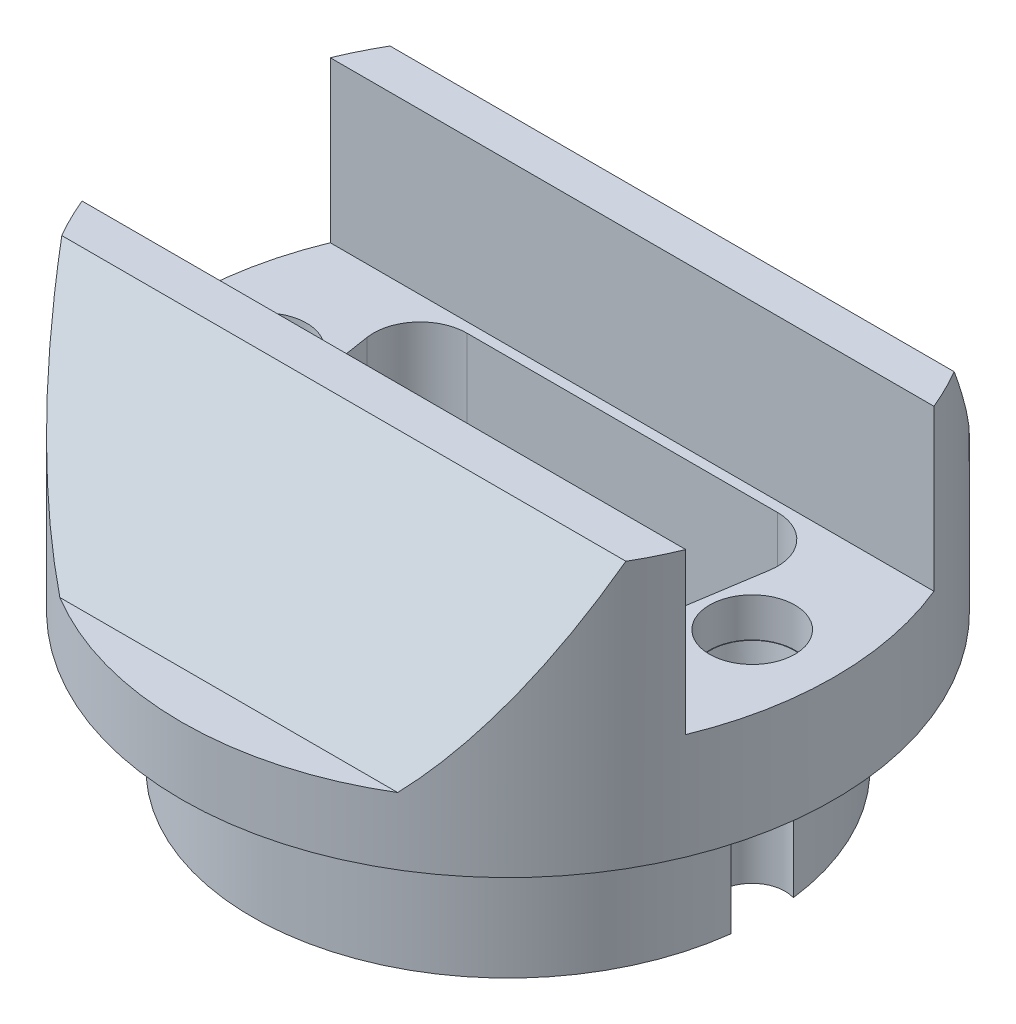
from build123d import *

# Parameters (mm, degrees)
SKETCH1_R           = 13.1
BOSS_EXTRUDE1_DEPTH = 7
SKETCH2_R           = 16.7
BOSS_EXTRUDE2_DEPTH = 3.429
CUT_EXTRUDE1_DEPTH  = 11.429
SKETCH5_R           = 2.159
CUT_EXTRUDE2_DEPTH  = 3.429
CUT_EXTRUDE2_TAPER  = 8
CUT_EXTRUDE3_DEPTH  = 8
SKETCH7_R           = 16.7
BOSS_EXTRUDE3_DEPTH = 10.2
SKETCH9_W           = 12.7
SKETCH9_H           = 10.2
CUT_EXTRUDE4_DEPTH  = 34.4
SKETCH10_R          = 2.1844
BOSS_EXTRUDE4_DEPTH = 2


with BuildPart() as part:
    # Sketch1 → Boss-Extrude1 (new body)
    with BuildSketch(Plane(origin=(0, 0, 0), x_dir=(1, 0, 0), z_dir=(0, 1, 0))):
        Circle(SKETCH1_R)
    extrude(amount=BOSS_EXTRUDE1_DEPTH)

    # Sketch2 → Boss-Extrude2 (add)
    with BuildSketch(Plane(origin=(0, 7, 0), x_dir=(1, 0, 0), z_dir=(0, 1, 0))):
        Circle(SKETCH2_R)
    extrude(amount=BOSS_EXTRUDE2_DEPTH)

    # Sketch3 → Cut-Extrude1 (cut, through all)
    with BuildSketch(Plane(origin=(0, 10.429, 0), x_dir=(1, 0, 0), z_dir=(0, 1, 0))):
        with BuildLine():
            Line((-9.229677532, -3.822990239), (-10.309177532, 3.085809761))
            ThreePointArc((-10.309177532, 3.085809761), (-9.764129411, 5.00691211), (-7.9502, 5.842))
            Line((-7.9502, 5.842), (7.9502, 5.842))
            ThreePointArc((7.9502, 5.842), (9.764129411, 5.00691211), (10.309177532, 3.085809761))
            Line((10.309177532, 3.085809761), (9.229677532, -3.822990239))
            ThreePointArc((9.229677532, -3.822990239), (8.42321211, -5.268329411), (6.8707, -5.842))
            Line((6.8707, -5.842), (-6.8707, -5.842))
            ThreePointArc((-6.8707, -5.842), (-8.42321211, -5.268329411), (-9.229677532, -3.822990239))
        make_face()
    extrude(amount=-CUT_EXTRUDE1_DEPTH, mode=Mode.SUBTRACT)

    # Sketch5 → Cut-Extrude2 (cut)
    with BuildSketch(Plane(origin=(0, 10.429, 0), x_dir=(1, 0, 0), z_dir=(0, 1, 0))):
        with Locations((12.4968, 0)):
            Circle(SKETCH5_R)
        with Locations((-12.4968, 0)):
            Circle(SKETCH5_R)
    extrude(amount=-CUT_EXTRUDE2_DEPTH, taper=CUT_EXTRUDE2_TAPER, mode=Mode.SUBTRACT)

    # Sketch6 → Cut-Extrude3 (cut, through all)
    with BuildSketch(Plane(origin=(0, 7, 0), x_dir=(1, 0, 0), z_dir=(0, 1, 0))):
        with BuildLine():
            ThreePointArc((13.0020243, -1.599176071), (13.1, 0), (13.0020243, 1.599176071))
            ThreePointArc((13.0020243, 1.599176071), (10.819714522, 0), (13.0020243, -1.599176071))
        make_face()
        with BuildLine():
            ThreePointArc((-13.0020243, 1.599176071), (-13.1, 0), (-13.0020243, -1.599176071))
            ThreePointArc((-13.0020243, -1.599176071), (-10.819714522, 0), (-13.0020243, 1.599176071))
        make_face()
    extrude(amount=-CUT_EXTRUDE3_DEPTH, mode=Mode.SUBTRACT)

    # Sketch7 → Boss-Extrude3 (add)
    with BuildSketch(Plane(origin=(0, 10.429, 0), x_dir=(1, 0, 0), z_dir=(0, 1, 0))):
        Circle(SKETCH7_R)
    extrude(amount=BOSS_EXTRUDE3_DEPTH)

    # Sketch9 → Cut-Extrude4 (cut, through all)
    with BuildSketch(Plane(origin=(16.7, 0, 0), x_dir=(0, 0, -1), z_dir=(1, 0, 0))):
        with Locations((0, 15.529)):
            Rectangle(SKETCH9_W, SKETCH9_H)
        Polygon((-17.46937566, 10.429), (-14.288972746, 10.429), (-8.4, 20.629), (-17.46937566, 20.629), align=None)
        Polygon((17.46937566, 20.629), (17.46937566, 10.429), (14.288972746, 10.429), (8.4, 20.629), align=None)
    extrude(amount=-CUT_EXTRUDE4_DEPTH, mode=Mode.SUBTRACT)

    # Sketch10 → Boss-Extrude4 (add)
    with BuildSketch(Plane(origin=(0, 10.429, 0), x_dir=(1, 0, 0), z_dir=(0, 1, 0))):
        with BuildLine():
            Line((15.44563045, 6.35), (-15.44563045, 6.35))
            ThreePointArc((-15.44563045, 6.35), (-16.7, 0), (-15.44563045, -6.35))
            Line((-15.44563045, -6.35), (15.44563045, -6.35))
            ThreePointArc((15.44563045, -6.35), (16.7, 0), (15.44563045, 6.35))
        make_face()
        with Locations((12.4968, 0)):
            Circle(SKETCH10_R, mode=Mode.SUBTRACT)
        with Locations((-12.4968, 0)):
            Circle(SKETCH10_R, mode=Mode.SUBTRACT)
        with BuildLine():
            Line((6.8707, -5.842), (-6.8707, -5.842))
            ThreePointArc((-6.8707, -5.842), (-8.42321211, -5.268329411), (-9.229677532, -3.822990239))
            Line((-9.229677532, -3.822990239), (-10.309177532, 3.085809761))
            ThreePointArc((-10.309177532, 3.085809761), (-9.764129411, 5.00691211), (-7.9502, 5.842))
            Line((-7.9502, 5.842), (7.9502, 5.842))
            ThreePointArc((7.9502, 5.842), (9.764129411, 5.00691211), (10.309177532, 3.085809761))
            Line((10.309177532, 3.085809761), (9.229677532, -3.822990239))
            ThreePointArc((9.229677532, -3.822990239), (8.42321211, -5.268329411), (6.8707, -5.842))
        make_face(mode=Mode.SUBTRACT)
    extrude(amount=BOSS_EXTRUDE4_DEPTH)


solid = part.part
